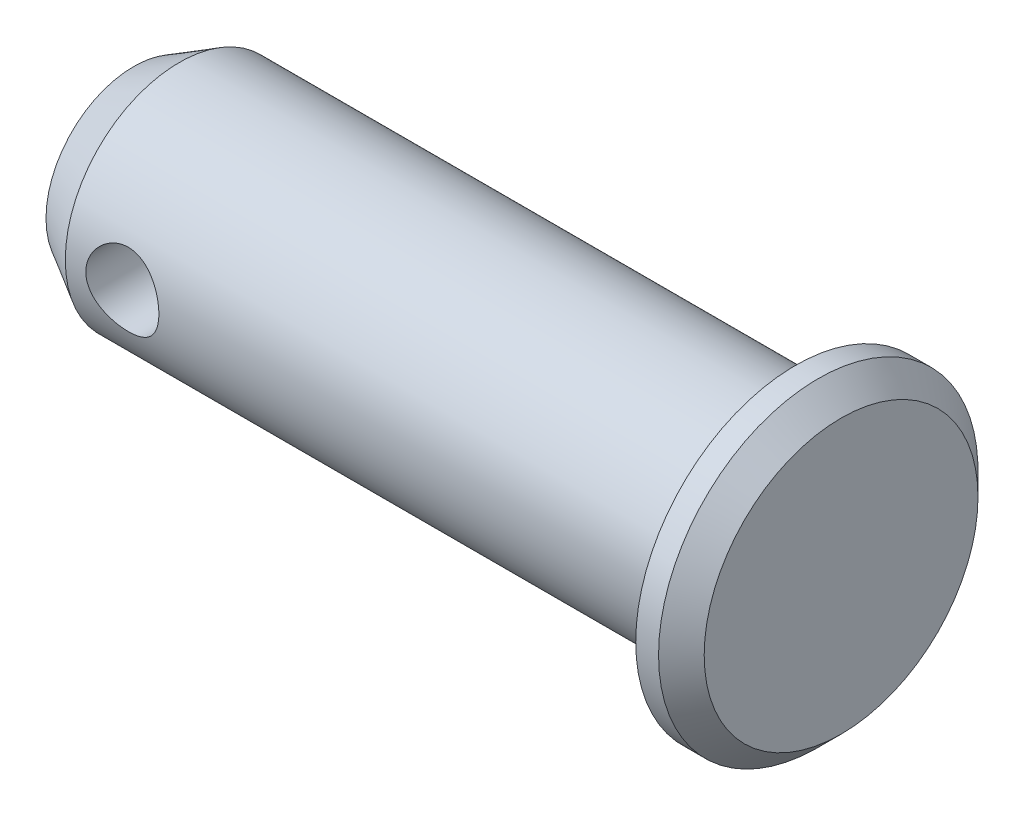
from build123d import *

# Parameters (mm, degrees)
SKETCH1_W              = 29
SKETCH1_H              = 5
HEAD_CHAMFER_SIZE      = 2
HEAD_CHAMFER_SIZE2     = 1.154700538
SKETCH21_R             = 1.6
R_CLIP_HOLE_DEPTH      = 8
R_CLIP_HOLE_DEPTH_BACK = 8


with BuildPart() as part:
    # Sketch1 → Body Revolve (revolve)
    with BuildSketch(Plane.XY):
        with Locations((-14.5, 2.5)):
            Rectangle(SKETCH1_W, SKETCH1_H)
    revolve(axis=Axis((0, 0, 0), (-1, 0, 0)))

    # Sketch14 → Head Revolve (revolve)
    with BuildSketch(Plane.XY):
        Polygon((0, 0), (2, 0), (2, 6), (1, 7), (0, 7), align=None)
    revolve(axis=Axis((0, 0, 0), (1, 0, 0)))

    # Head Chamfer
    head_chamfer_edges = [part.edges().sort_by_distance(p)[0] for p in [
        (-29, -5, 0),
    ]]
    head_chamfer_side = [part.faces().sort_by_distance(p)[0] for p in [
        (-14.5, -5, 0),
    ]]
    chamfer(head_chamfer_edges, length=HEAD_CHAMFER_SIZE, length2=HEAD_CHAMFER_SIZE2, reference=head_chamfer_side[0])

    # Sketch21 → R Clip Hole (cut, two sides)
    with BuildSketch(Plane.XY) as r_clip_hole_sk:
        with Locations((-24.5, 0)):
            Circle(SKETCH21_R)
    extrude(amount=R_CLIP_HOLE_DEPTH, mode=Mode.SUBTRACT)
    extrude(r_clip_hole_sk.sketch, amount=-R_CLIP_HOLE_DEPTH_BACK, mode=Mode.SUBTRACT)


solid = part.part
